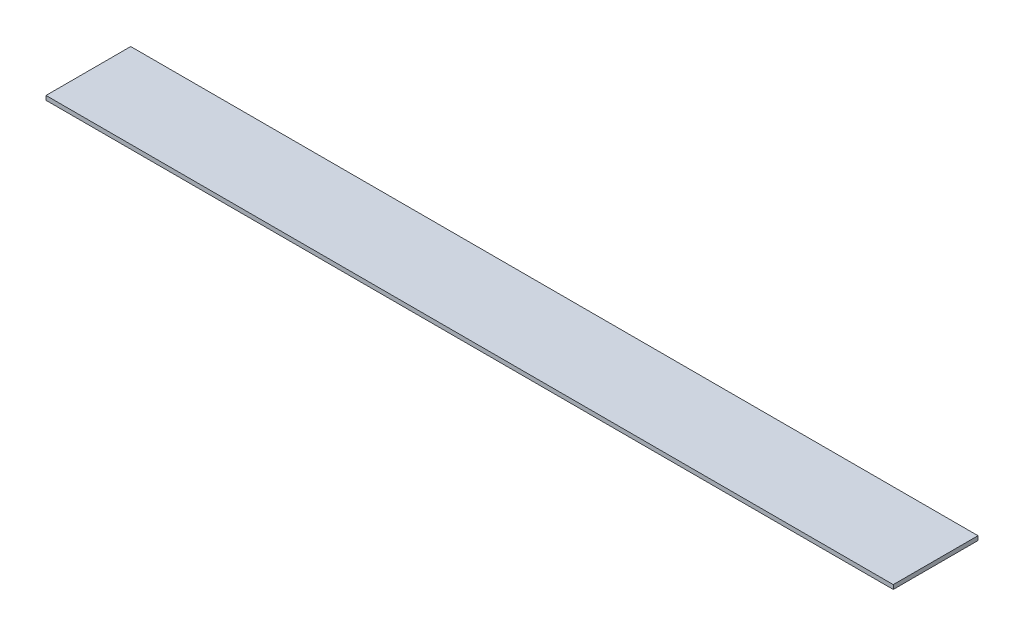
from build123d import *

# Parameters (mm, degrees)
SKETCH_1_W      = 2000
SKETCH_1_H      = 200
EXTRUDE_1_DEPTH = 10


with BuildPart() as part:
    # 草图1 → 凸台-拉伸1 (new body)
    with BuildSketch(Plane(origin=(0, 0, 0), x_dir=(1, 0, 0), z_dir=(0, 1, 0))):
        Rectangle(SKETCH_1_W, SKETCH_1_H)
    extrude(amount=EXTRUDE_1_DEPTH)


solid = part.part
